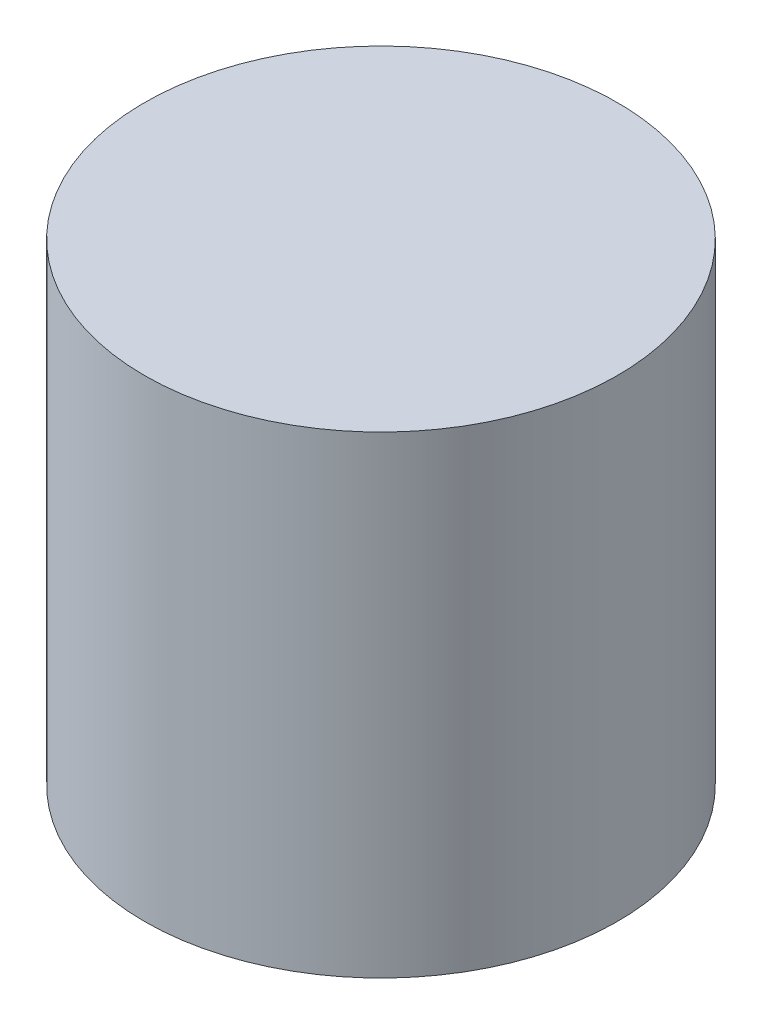
from build123d import *

# Parameters (mm, degrees)
SKETCH1_R           = 63.5
BOSS_EXTRUDE1_DEPTH = 127


with BuildPart() as part:
    # Sketch1 → Boss-Extrude1 (new body)
    with BuildSketch(Plane(origin=(0, 0, 0), x_dir=(1, 0, 0), z_dir=(0, 1, 0))):
        with Locations((-53.731625514, 16.252158335)):
            Circle(SKETCH1_R)
    extrude(amount=BOSS_EXTRUDE1_DEPTH)


solid = part.part
